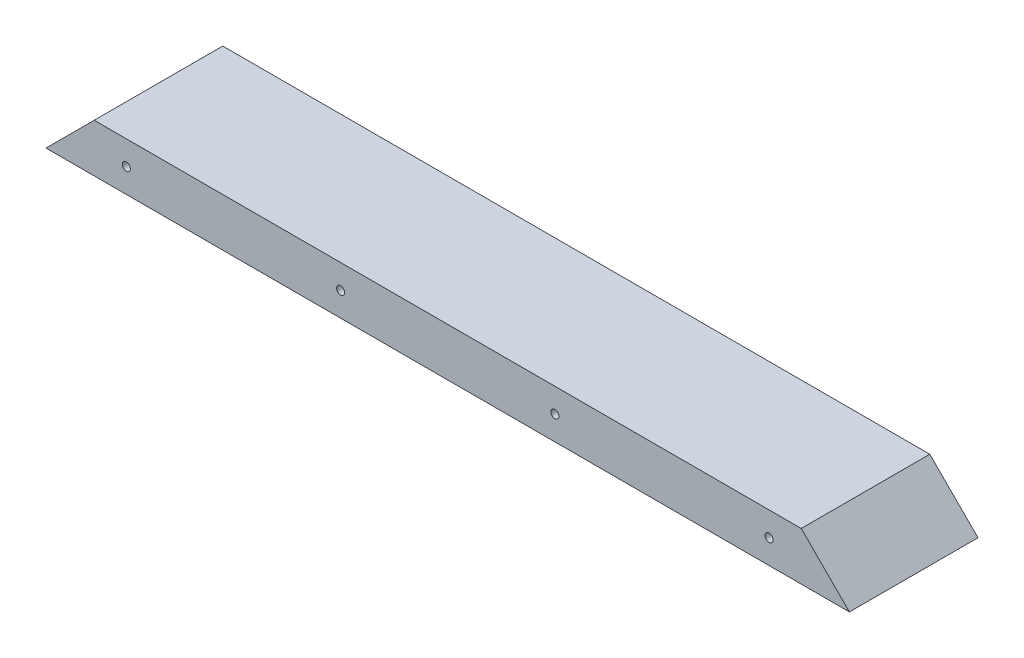
from build123d import *

# Parameters (mm, degrees)
SALIENTE_EXTRUIR1_DEPTH = 250
CROQUIS2_R              = 1.25
CORTAR_EXTRUIR1_DEPTH   = 41


with BuildPart() as part:
    # Croquis1 → Saliente-Extruir1 (new body)
    with BuildSketch(Plane(origin=(0, 0, 0), x_dir=(0, 0, -1), z_dir=(1, 0, 0))):
        Polygon((-20, 0), (20, 0), (20, 15), (18.5, 15), (-18.5, 15), (-20, 15), align=None)
    extrude(amount=SALIENTE_EXTRUIR1_DEPTH)

    # Croquis2 → Cortar-Extruir1 (cut, through all)
    with BuildSketch(Plane(origin=(0, 0, -20), x_dir=(-1, 0, 0), z_dir=(0, 0, -1))):
        with Locations((-225, 7.5)):
            Circle(CROQUIS2_R)
        with Locations((-25, 7.5)):
            Circle(CROQUIS2_R)
        with Locations((-158.333333333, 7.5)):
            Circle(CROQUIS2_R)
        with Locations((-91.666666667, 7.5)):
            Circle(CROQUIS2_R)
        Polygon((0, 15), (-15, 15), (0, 0), align=None)
        Polygon((-250, 15), (-235, 15), (-250, 0), align=None)
    extrude(amount=-CORTAR_EXTRUIR1_DEPTH, mode=Mode.SUBTRACT)


solid = part.part
